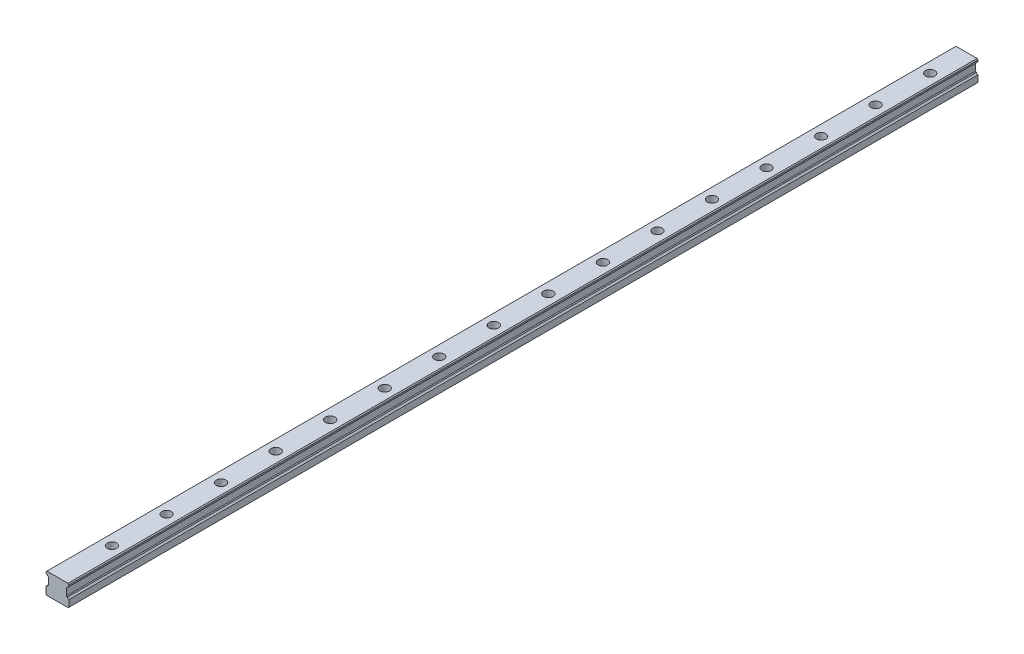
from build123d import *

# Parameters (mm, degrees)
RESSALTO_EXTRUS_O1_DEPTH                             = 2500
REBAIXO_PARA_PARAFUSO_DE_CABE_A_SEXTAVAD_D           = 18
REBAIXO_PARA_PARAFUSO_DE_CABE_A_SEXTAVAD_DEPTH       = 58
REBAIXO_PARA_PARAFUSO_DE_CABE_A_SEXTAVAD_CBORE_D     = 26
REBAIXO_PARA_PARAFUSO_DE_CABE_A_SEXTAVAD_CBORE_DEPTH = 25
CHANFRO1_SIZE2                                       = 2.500287455
CHANFRO1_SIZE                                        = 2.500257245
CHANFRO2_SIZE2                                       = 2.500423779
CHANFRO2_SIZE                                        = 2.500287455
CHANFRO3_SIZE                                        = 2


with BuildPart() as part:
    # Esboço1 → Ressalto-extrusão1 (new body)
    with BuildSketch(Plane.XY):
        with BuildLine():
            Line((-31.5, 20.527298986), (-31.5, 0))
            Line((-31.5, 0), (31.5, 0))
            Line((31.5, 0), (31.5, 20.527298986))
            ThreePointArc((31.5, 20.527298986), (28.900076881, 22.150342104), (27.397266061, 24.82156445))
            Line((27.397266061, 24.82156445), (24.5, 25.597882749))
            Line((24.5, 25.597882749), (24.5, 46.397686197))
            Line((24.5, 46.397686197), (27.397119712, 47.17387922))
            ThreePointArc((27.397119712, 47.17387922), (28.898613337, 49.848990738), (31.5, 51.474872705))
            Line((31.5, 51.474872705), (31.5, 58))
            Line((31.5, 58), (-31.5, 58))
            Line((-31.5, 58), (-31.5, 51.474872705))
            ThreePointArc((-31.5, 51.474872705), (-28.899411057, 49.849685923), (-27.397802135, 47.175837466))
            Line((-27.397802135, 47.175837466), (-24.5, 46.399706372))
            Line((-24.5, 46.399706372), (-24.5, 25.596973237))
            Line((-24.5, 25.596973237), (-27.397939574, 24.823365186))
            ThreePointArc((-27.397939574, 24.823365186), (-28.900095464, 22.151244343), (-31.5, 20.527298986))
        make_face()
    extrude(amount=RESSALTO_EXTRUS_O1_DEPTH)

    # Rebaixo para parafuso de cabeça sextavada de M161
    with Locations(Plane(origin=(0, 58, 0), x_dir=(1, 0, 0), z_dir=(0, 1, 0))):
        with Locations((0, -100), (0, -250), (0, -400), (0, -550), (0, -700), (0, -850), (0, -1000), (0, -1150), (0, -1300), (0, -1450), (0, -1600), (0, -1750), (0, -1900), (0, -2050), (0, -2200), (0, -2350)):
            CounterBoreHole(REBAIXO_PARA_PARAFUSO_DE_CABE_A_SEXTAVAD_D / 2, REBAIXO_PARA_PARAFUSO_DE_CABE_A_SEXTAVAD_CBORE_D / 2, REBAIXO_PARA_PARAFUSO_DE_CABE_A_SEXTAVAD_CBORE_DEPTH, depth=REBAIXO_PARA_PARAFUSO_DE_CABE_A_SEXTAVAD_DEPTH)

    # Chanfro1
    chanfro1_edges = [part.edges().sort_by_distance(p)[0] for p in [
        (-31.5, 58, 1250),
    ]]
    chamfer(chanfro1_edges, length=CHANFRO1_SIZE, length2=CHANFRO1_SIZE2)

    # Chanfro2
    chanfro2_edges = [part.edges().sort_by_distance(p)[0] for p in [
        (31.5, 58, 1250),
    ]]
    chamfer(chanfro2_edges, length=CHANFRO2_SIZE, length2=CHANFRO2_SIZE2)

    # Chanfro3
    chanfro3_edges = [part.edges().sort_by_distance(p)[0] for p in [
        (31.5, 0, 1250),
        (-31.5, 0, 1250),
    ]]
    chamfer(chanfro3_edges, length=CHANFRO3_SIZE)


solid = part.part
